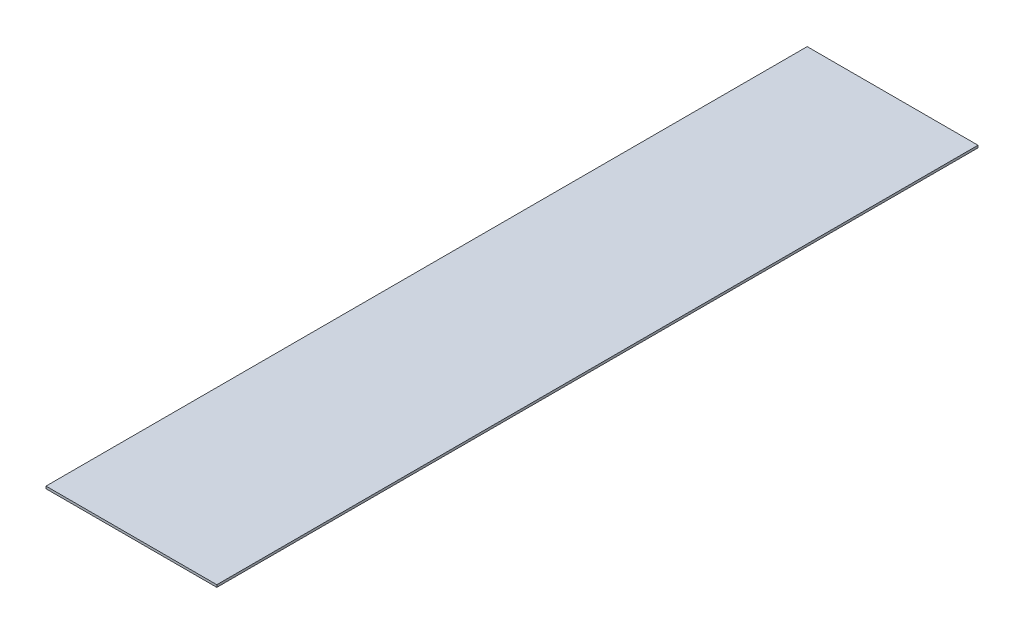
from build123d import *

# Parameters (mm, degrees)
SKETCH1_W           = 185.42
SKETCH1_H           = 826.262
BOSS_EXTRUDE1_DEPTH = 2.54


with BuildPart() as part:
    # Sketch1 → Boss-Extrude1 (new body)
    with BuildSketch(Plane(origin=(0, 0, 0), x_dir=(1, 0, 0), z_dir=(0, 1, 0))):
        with Locations((-273.147303483, -82.215124378)):
            Rectangle(SKETCH1_W, SKETCH1_H)
    extrude(amount=BOSS_EXTRUDE1_DEPTH)


solid = part.part
